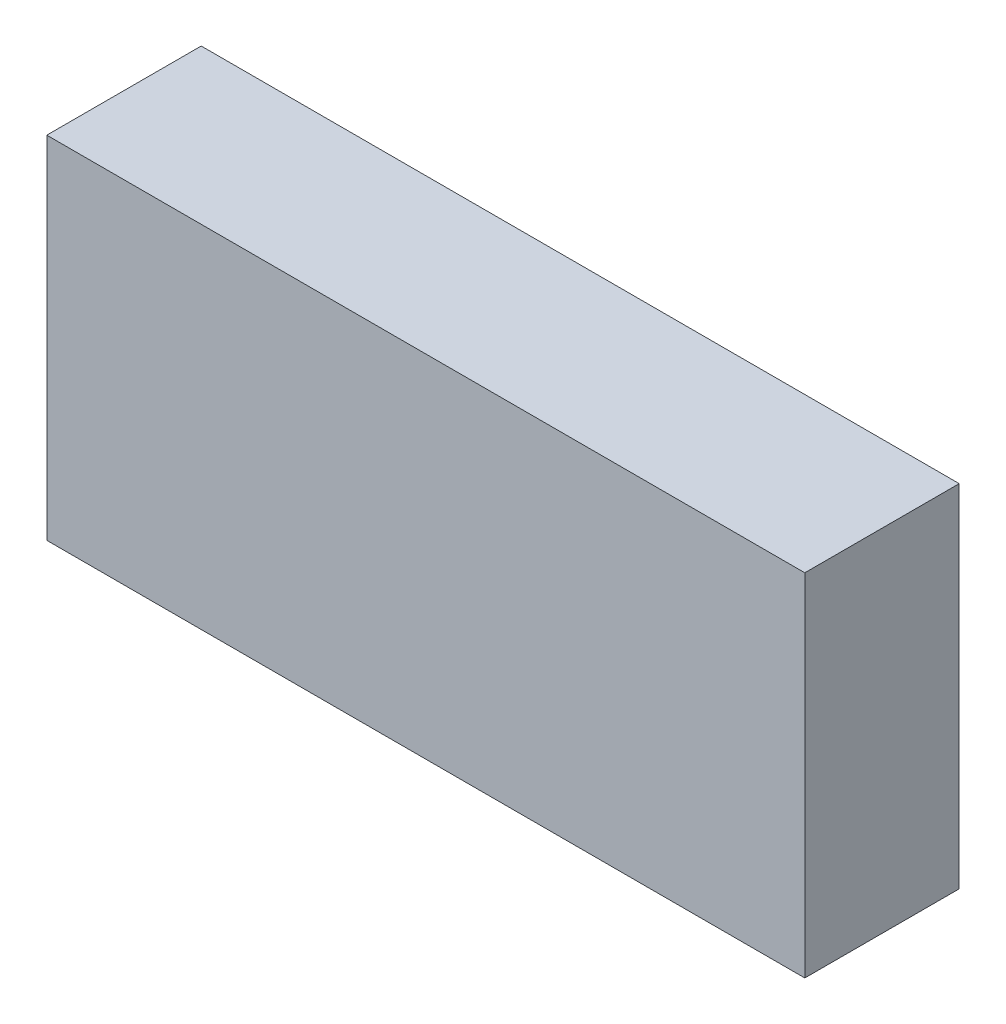
from build123d import *

# Parameters (mm, degrees)
ESBO_O1_W                = 54
ESBO_O1_H                = 25
RESSALTO_EXTRUS_O1_DEPTH = 11


with BuildPart() as part:
    # Esboço1 → Ressalto-extrusão1 (new body)
    with BuildSketch(Plane.XY):
        with Locations((27, -12.5)):
            Rectangle(ESBO_O1_W, ESBO_O1_H)
    extrude(amount=RESSALTO_EXTRUS_O1_DEPTH)


solid = part.part
